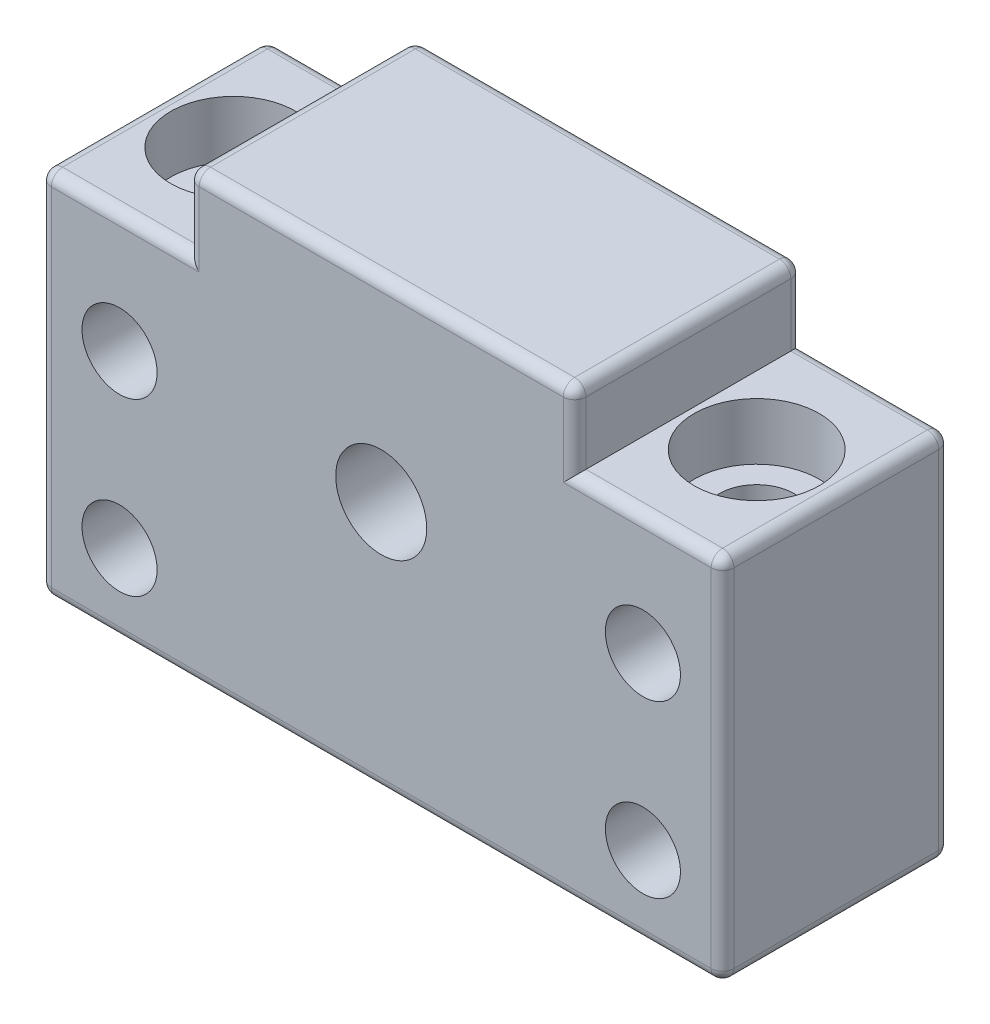
from build123d import *

# Parameters (mm, degrees)
SKETCH_1_W               = 60
SKETCH_1_H               = 32.5
SKETCH_1_R               = 4
SKETCH_1_R_2             = 3.3
SKETCH_1_W_2             = 34
SKETCH_1_H_2             = 6.5
EXTRUDE_1_DEPTH          = 20
SKETCH_4_R               = 5.5
CUT_EXTRUDE_1_DEPTH      = 49.541219597
CUT_EXTRUDE_1_DEPTH_BACK = 5
FILLET_1_R               = 1
FILLET_2_R               = 1
FILLET_4_R               = 1
FILLET_5_R               = 1
FILLET_6_R               = 1
FILLET_7_R               = 1
FILLET_8_R               = 1
FILLET_9_R               = 1
FILLET_10_R              = 1
FILLET_11_R              = 1
FILLET_12_R              = 1
SKETCH_5_R               = 3.3
CUT_EXTRUDE_2_DEPTH      = 89


with BuildPart() as part:
    # 草图1 → 凸台-拉伸1 (new body)
    with BuildSketch(Plane.XY):
        Rectangle(SKETCH_1_W, SKETCH_1_H)
        with Locations((0, 5.75)):
            Circle(SKETCH_1_R, mode=Mode.SUBTRACT)
        with Locations((-23, 5.75)):
            Circle(SKETCH_1_R_2, mode=Mode.SUBTRACT)
        with Locations((-23, -9.25)):
            Circle(SKETCH_1_R_2, mode=Mode.SUBTRACT)
        with Locations((23, -9.25)):
            Circle(SKETCH_1_R_2, mode=Mode.SUBTRACT)
        with Locations((23, 5.75)):
            Circle(SKETCH_1_R_2, mode=Mode.SUBTRACT)
        with Locations((0, 19.5)):
            Rectangle(SKETCH_1_W_2, SKETCH_1_H_2)
    extrude(amount=EXTRUDE_1_DEPTH)

    # 草图4 → 切除-拉伸1 (cut, two sides)
    with BuildSketch(Plane(origin=(0, 16.25, 0), x_dir=(1, 0, 0), z_dir=(0, 1, 0))) as cut_extrude_1_sk:
        with Locations(Location((-23, -10, 0), (0, 0, 270))):
            Circle(SKETCH_4_R)
        with Locations(Location((23, -10, 0), (0, 0, 270))):
            Circle(SKETCH_4_R)
    extrude(amount=CUT_EXTRUDE_1_DEPTH, mode=Mode.SUBTRACT)
    extrude(cut_extrude_1_sk.sketch, amount=-CUT_EXTRUDE_1_DEPTH_BACK, mode=Mode.SUBTRACT)

    # 圆角1
    fillet_1_edges = [part.edges().sort_by_distance(p)[0] for p in [
        (-17, 22.75, 10),
    ]]
    fillet(fillet_1_edges, radius=FILLET_1_R)

    # 圆角2
    fillet_2_edges = [part.edges().sort_by_distance(p)[0] for p in [
        (17, 22.75, 10),
    ]]
    fillet(fillet_2_edges, radius=FILLET_2_R)

    # 圆角4
    fillet_4_edges = [part.edges().sort_by_distance(p)[0] for p in [
        (30, 16.25, 10),
    ]]
    fillet(fillet_4_edges, radius=FILLET_4_R)

    # 圆角5
    fillet_5_edges = [part.edges().sort_by_distance(p)[0] for p in [
        (-30, 16.25, 10),
    ]]
    fillet(fillet_5_edges, radius=FILLET_5_R)

    # 圆角6
    fillet_6_edges = [part.edges().sort_by_distance(p)[0] for p in [
        (-17, 19, 20),
        (0, 22.75, 20),
        (-16.707106781, 22.457106781, 20),
        (17, 19, 20),
        (16.707106781, 22.457106781, 20),
    ]]
    fillet(fillet_6_edges, radius=FILLET_6_R)

    # 圆角7
    fillet_7_edges = [part.edges().sort_by_distance(p)[0] for p in [
        (-17, 19, 0),
        (0, 22.75, 0),
        (-16.707106781, 22.457106781, 0),
        (17, 19, 0),
        (16.707106781, 22.457106781, 0),
    ]]
    fillet(fillet_7_edges, radius=FILLET_7_R)

    # 圆角8
    fillet_8_edges = [part.edges().sort_by_distance(p)[0] for p in [
        (-22.5, 16.25, 20),
        (-30, -0.5, 20),
        (-29.707106781, 15.957106781, 20),
    ]]
    fillet(fillet_8_edges, radius=FILLET_8_R)

    # 圆角9
    fillet_9_edges = [part.edges().sort_by_distance(p)[0] for p in [
        (22.5, 16.25, 20),
        (30, -0.5, 20),
        (29.707106781, 15.957106781, 20),
    ]]
    fillet(fillet_9_edges, radius=FILLET_9_R)

    # 圆角10
    fillet_10_edges = [part.edges().sort_by_distance(p)[0] for p in [
        (22.5, 16.25, 0),
        (30, -0.5, 0),
        (29.707106781, 15.957106781, 0),
    ]]
    fillet(fillet_10_edges, radius=FILLET_10_R)

    # 圆角11
    fillet_11_edges = [part.edges().sort_by_distance(p)[0] for p in [
        (-22.5, 16.25, 0),
        (-30, -0.5, 0),
        (-29.707106781, 15.957106781, 0),
    ]]
    fillet(fillet_11_edges, radius=FILLET_11_R)

    # 圆角12
    fillet_12_edges = [part.edges().sort_by_distance(p)[0] for p in [
        (-30, -16.25, 10),
        (0, -16.25, 20),
        (-29.707106781, -16.25, 19.707106781),
        (30, -16.25, 10),
        (29.707106781, -16.25, 19.707106781),
        (29.707106781, -16.25, 0.292893219),
        (0, -16.25, 0),
        (-29.707106781, -16.25, 0.292893219),
    ]]
    fillet(fillet_12_edges, radius=FILLET_12_R)

    # 草图5 → 切除-拉伸2 (cut)
    with BuildSketch(Plane(origin=(0, 11.25, 0), x_dir=(1, 0, 0), z_dir=(0, 1, 0))):
        with Locations(Location((-23, -10, 0), (0, 0, 270))):
            Circle(SKETCH_5_R)
        with Locations(Location((23, -10, 0), (0, 0, 270))):
            Circle(SKETCH_5_R)
    extrude(amount=-CUT_EXTRUDE_2_DEPTH, mode=Mode.SUBTRACT)


solid = part.part
